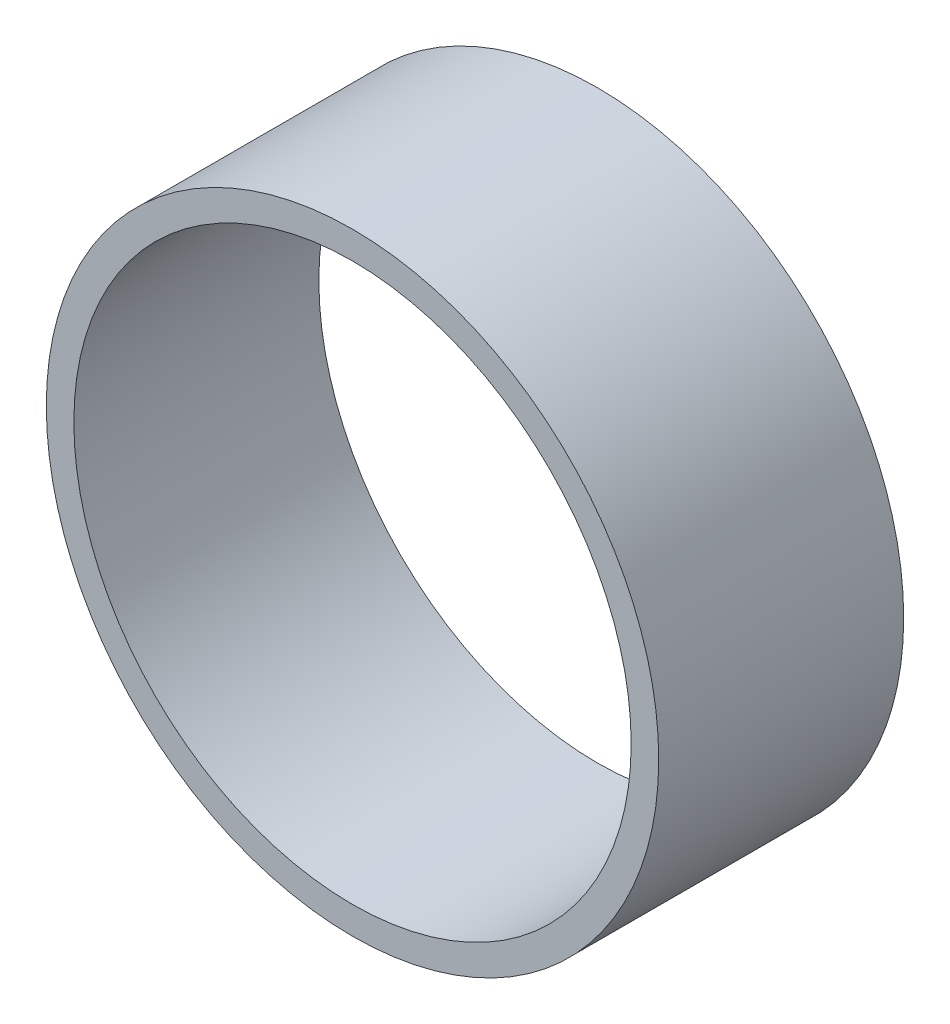
from build123d import *

# Parameters (mm, degrees)
SKETCH1_R           = 5
SKETCH1_R_2         = 4.55
BOSS_EXTRUDE1_DEPTH = 4


with BuildPart() as part:
    # Sketch1 → Boss-Extrude1 (new body)
    with BuildSketch(Plane.XY):
        Circle(SKETCH1_R)
        Circle(SKETCH1_R_2, mode=Mode.SUBTRACT)
    extrude(amount=BOSS_EXTRUDE1_DEPTH)


solid = part.part
